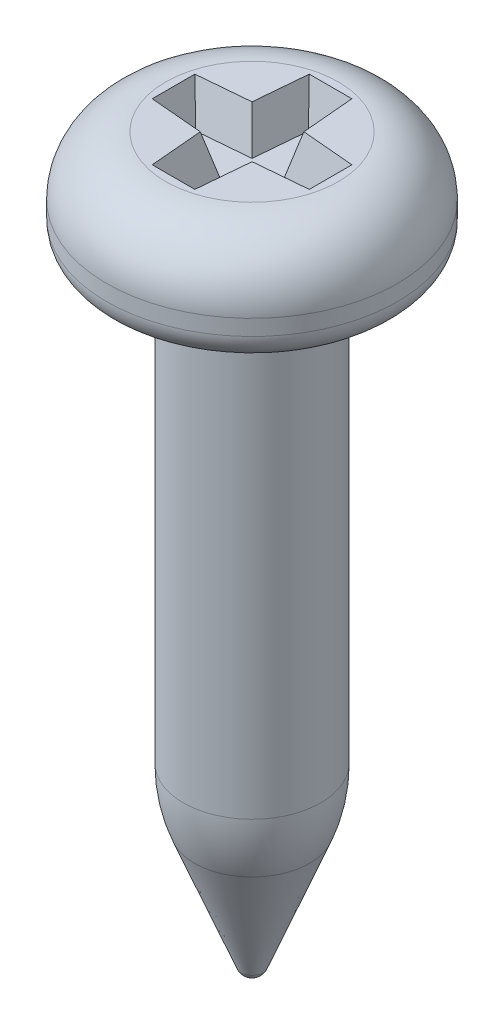
from build123d import *

# Parameters (mm, degrees)
CUT_EXTRUDE1_DEPTH = 0.5
CUT_EXTRUDE1_TAPER = 15


with BuildPart() as part:
    # Sketch1 → Revolve1 (revolve)
    with BuildSketch(Plane.XY):
        with BuildLine():
            Line((0.875, -6.964405423), (0.875, -1.45))
            ThreePointArc((0.875, -1.45), (0.918933983, -1.343933983), (1.025, -1.3))
            Line((1.025, -1.3), (1.5, -1.3))
            ThreePointArc((1.5, -1.3), (1.747487373, -1.197487373), (1.85, -0.95))
            Line((1.85, -0.95), (1.85, -0.75))
            ThreePointArc((1.85, -0.75), (1.630330086, -0.219669914), (1.1, 0))
            Line((1.1, 0), (0, 0))
            Line((0, 0), (0, -9.3))
            ThreePointArc((0, -9.3), (0.084334338, -9.274047247), (0.139485899, -9.205169593))
            Line((0.139485899, -9.205169593), (0.734811985, -7.7))
            ThreePointArc((0.734811985, -7.7), (0.839640421, -7.338822324), (0.875, -6.964405423))
        make_face()
    revolve(axis=Axis((0, 0, 0), (0, -1, 0)))

    # Sketch2 → Cut-Extrude1 (cut)
    with BuildSketch(Plane(origin=(0, 0, 0), x_dir=(1, 0, 0), z_dir=(0, 1, 0))):
        Polygon((-0.271382595, 1), (-0.33, 0.33), (-1, 0.271382595), (-1, -0.271382595), (-0.33, -0.33), (-0.271382595, -1), (0.271382595, -1), (0.33, -0.33), (1, -0.271382595), (1, 0.271382595), (0.33, 0.33), (0.271382595, 1), align=None)
    extrude(amount=-CUT_EXTRUDE1_DEPTH, taper=CUT_EXTRUDE1_TAPER, mode=Mode.SUBTRACT)


solid = part.part
